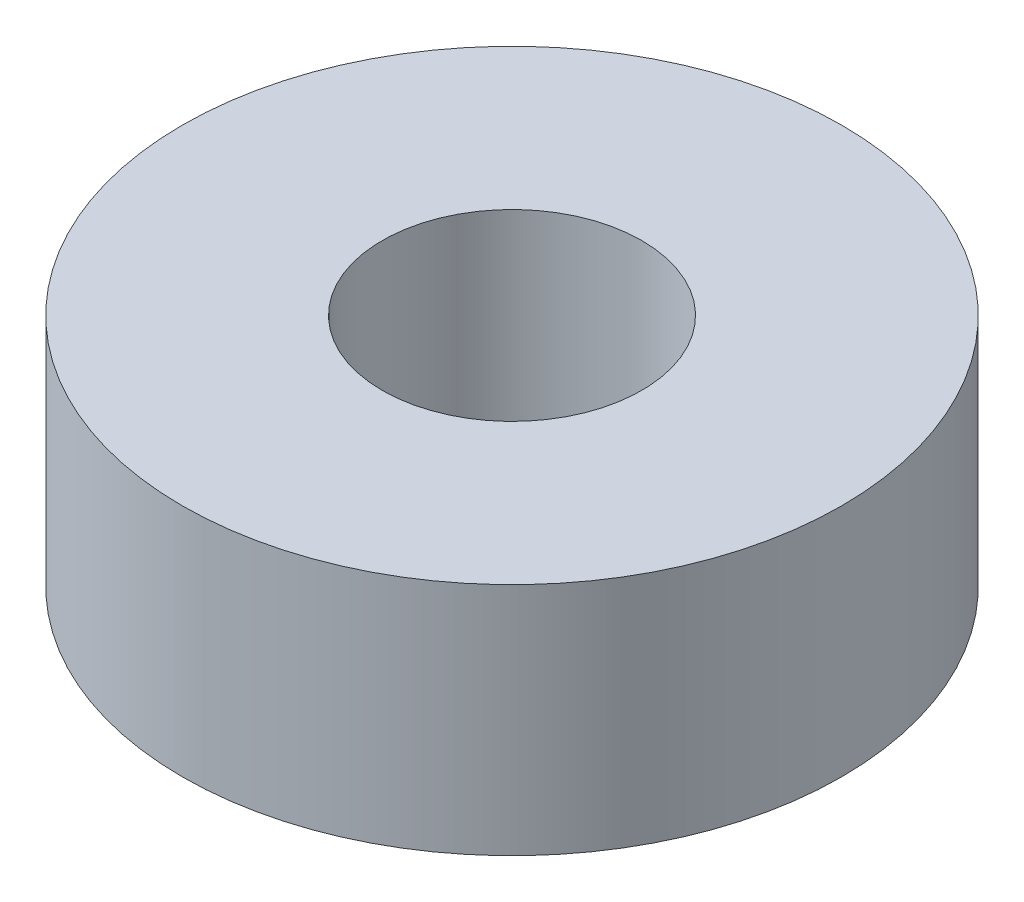
from build123d import *

# Parameters (mm, degrees)
SKETCH1_R           = 6.35
SKETCH1_R_2         = 2.5
BOSS_EXTRUDE1_DEPTH = 4.5212


with BuildPart() as part:
    # Sketch1 → Boss-Extrude1 (new body)
    with BuildSketch(Plane(origin=(0, 0, 0), x_dir=(1, 0, 0), z_dir=(0, 1, 0))):
        Circle(SKETCH1_R)
        Circle(SKETCH1_R_2, mode=Mode.SUBTRACT)
    extrude(amount=BOSS_EXTRUDE1_DEPTH)


solid = part.part
